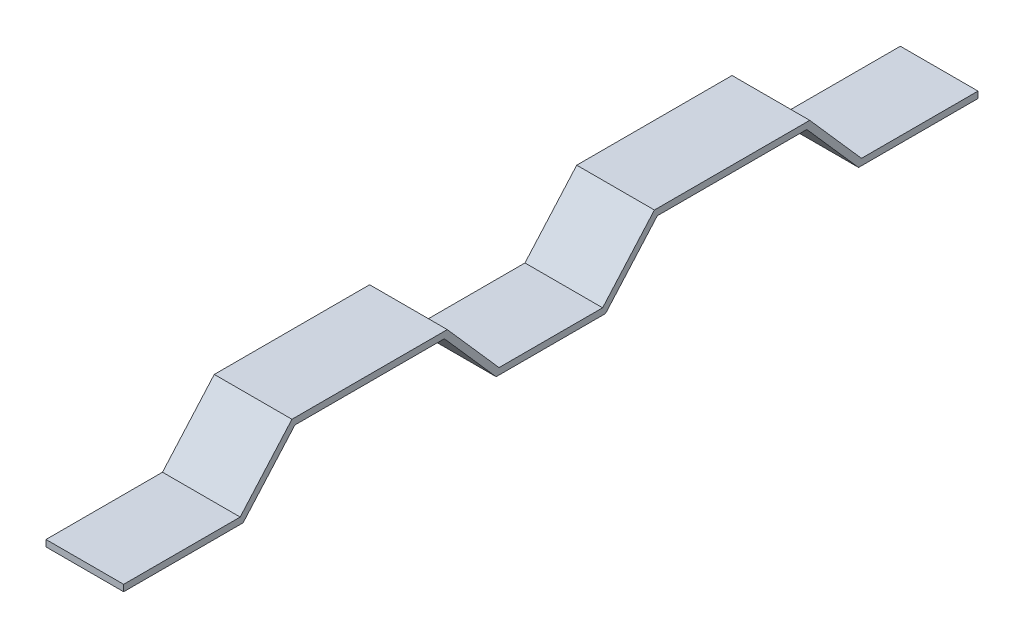
from build123d import *

# Parameters (mm, degrees)
BOSS_EXTRUDE1_DEPTH = 38.1


with BuildPart() as part:
    # Sketch1 → Boss-Extrude1 (new body)
    with BuildSketch(Plane(origin=(0, 0, 0), x_dir=(0, 0, -1), z_dir=(1, 0, 0))):
        Polygon((-174.463559322, 0), (-117.313559322, 0), (-91.913559322, 28.844067797), (-15.713559322, 28.844067797), (9.686440678, 0), (60.486440678, 0), (85.886440678, 28.844067797), (162.086440678, 28.844067797), (187.486440678, 0), (244.636440678, 0), (244.636440678, -3.175), (186.051773972, -3.175), (160.651773972, 25.669067797), (87.321107384, 25.669067797), (61.921107384, -3.175), (8.251773972, -3.175), (-17.148226028, 25.669067797), (-90.478892616, 25.669067797), (-115.878892616, -3.175), (-174.463559322, -3.175), align=None)
    extrude(amount=BOSS_EXTRUDE1_DEPTH)


solid = part.part
